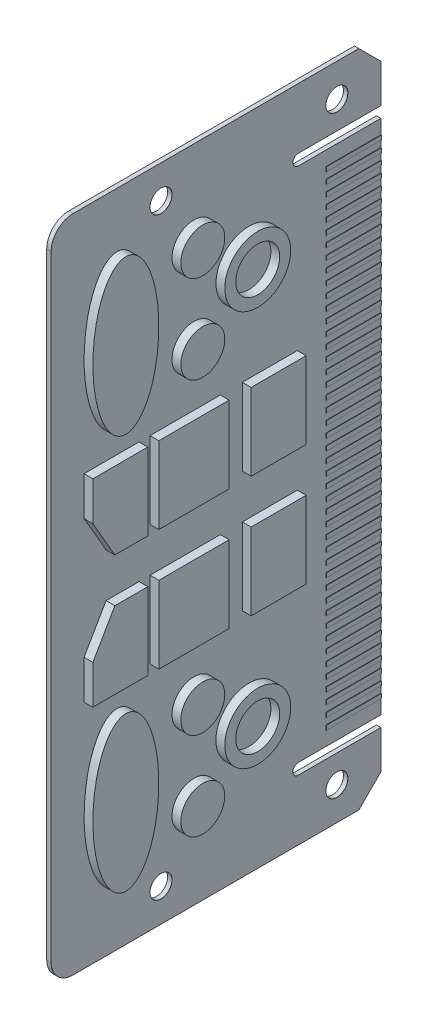
from build123d import *

# Parameters (mm, degrees)
SKETCH2_W                        = 300
SKETCH2_H                        = 150
BASE_DEPTH                       = 1
SKETCH3_R                        = 10
SKETCH3_R_2                      = 15
SKETCH3_RX                       = 35
SKETCH3_RY                       = 15
SKETCH3_W                        = 35
SKETCH3_H                        = 25
SKETCH3_H_2                      = 32
CHIPS_DEPTH                      = 4
SLOT_CUT_DEPTH                   = 4
F_10_0MM_DOWEL_HOLE2_D           = 10
F_10_0MM_DOWEL_HOLE2_CSINK_D     = 10.05
F_10_0MM_DOWEL_HOLE2_CSINK_ANGLE = 90
SKETCH11_W                       = 2
SKETCH11_H                       = 25
CONTACT_DEPTH                    = 0.2
CONTACT_PATTERN_COUNT            = 45
CONTACT_PATTERN_PITCH            = 5
FILLET1_R                        = 10
CHAMFER1_SIZE                    = 10


with BuildPart() as part:
    # Sketch2 → base (new body, symmetric)
    with BuildSketch(Plane.YZ):
        with Locations((-150, 75)):
            Rectangle(SKETCH2_W, SKETCH2_H)
    extrude(amount=BASE_DEPTH, both=True)

    # Sketch3 → chips (add)
    with BuildSketch(Plane.YZ.offset(1)):
        with Locations((-260, 85)):
            Circle(SKETCH3_R)
        with Locations((-220, 85)):
            Circle(SKETCH3_R)
        with Locations((-240, 60)):
            Circle(SKETCH3_R_2)
        with Locations((-240, 60)):
            Circle(SKETCH3_R, mode=Mode.SUBTRACT)
        with Locations((-60, 60)):
            Circle(SKETCH3_R_2)
        with Locations((-60, 60)):
            Circle(SKETCH3_R, mode=Mode.SUBTRACT)
        with Locations((-80, 85)):
            Circle(SKETCH3_R)
        with Locations((-40, 85)):
            Circle(SKETCH3_R)
        with Locations((-240, 120)):
            Ellipse(SKETCH3_RX, SKETCH3_RY)
        with Locations(Location((-60, 120), (0, 0, 180))):
            Ellipse(SKETCH3_RX, SKETCH3_RY)
        with Locations((-177.5, 50.5)):
            Rectangle(SKETCH3_W, SKETCH3_H)
        with Locations((-177.5, 89)):
            Rectangle(SKETCH3_W, SKETCH3_H_2)
        Polygon((-195, 135), (-177.320508076, 135), (-160, 125), (-160, 110), (-195, 110), align=None)
        Polygon((-122.679491924, 135), (-140, 125), (-140, 110), (-105, 110), (-105, 135), align=None)
        with Locations((-122.5, 89)):
            Rectangle(SKETCH3_W, SKETCH3_H_2)
        with Locations((-122.5, 50.5)):
            Rectangle(SKETCH3_W, SKETCH3_H)
    chips = extrude(amount=CHIPS_DEPTH)

    # mirror_chips: chips across plane
    add(chips.mirror(Plane(origin=(0, 0, 0), x_dir=(0, 0, 1), z_dir=(1, 0, 0))))

    # Sketch4 → slot_cut (cut)
    with BuildSketch(Plane.YZ.offset(1)):
        with BuildLine():
            Line((-272.5, 37.5), (-272.5, 0))
            Line((-272.5, 0), (-267.5, 0))
            Line((-267.5, 0), (-267.5, 37.5))
            ThreePointArc((-267.5, 37.5), (-270, 40), (-272.5, 37.5))
        make_face()
        with BuildLine():
            Line((-32.5, 0), (-32.5, 37.5))
            ThreePointArc((-32.5, 37.5), (-30, 40), (-27.5, 37.5))
            Line((-27.5, 37.5), (-27.5, 0))
            Line((-27.5, 0), (-32.5, 0))
        make_face()
    extrude(amount=-SLOT_CUT_DEPTH, mode=Mode.SUBTRACT)

    # Ø10.0mm Dowel Hole2 (through all)
    with Locations(Plane(origin=(1, -285, 100), x_dir=(0, 0, 1), z_dir=(1, 0, 0))):
        with Locations((0, 0), (-80, 0), (-80, -270), (0, -270)):
            CounterSinkHole(F_10_0MM_DOWEL_HOLE2_D / 2, F_10_0MM_DOWEL_HOLE2_CSINK_D / 2, counter_sink_angle=F_10_0MM_DOWEL_HOLE2_CSINK_ANGLE)

    # Sketch11 → contact (add)
    with BuildSketch(Plane.YZ.offset(1)):
        with Locations((-260, 12.5)):
            Rectangle(SKETCH11_W, SKETCH11_H)
    contact = extrude(amount=CONTACT_DEPTH)

    # contact_pattern: contact ×45
    with Locations(*[(0, i * CONTACT_PATTERN_PITCH, 0) for i in range(1, CONTACT_PATTERN_COUNT)]):
        add(contact)

    # Fillet1
    fillet1_edges = [part.edges().sort_by_distance(p)[0] for p in [
        (0, -300, 150),
        (0, 0, 150),
    ]]
    fillet(fillet1_edges, radius=FILLET1_R)

    # Chamfer1
    chamfer1_edges = [part.edges().sort_by_distance(p)[0] for p in [
        (0, 0, 0),
        (0, -300, 0),
    ]]
    chamfer(chamfer1_edges, length=CHAMFER1_SIZE)


solid = part.part
